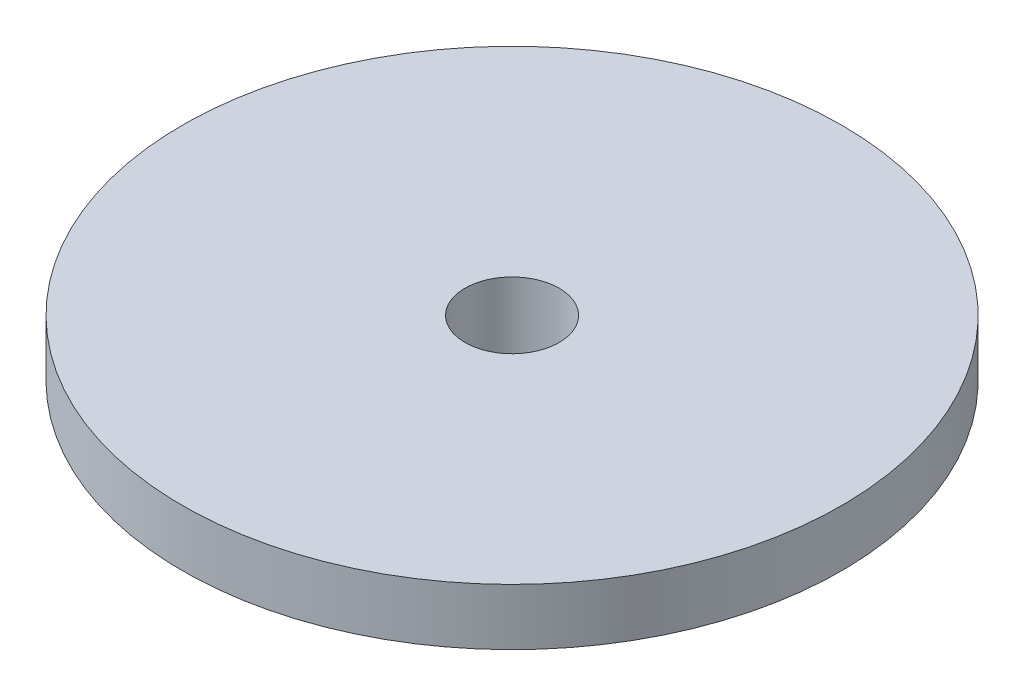
from build123d import *

# Parameters (mm, degrees)
SKETCH10_R         = 2.5
CUT_EXTRUDE1_DEPTH = 11
SKETCH11_R         = 4.5
CUT_EXTRUDE2_DEPTH = 5


with BuildPart() as part:
    # Sketch1 → Revolve1 (revolve)
    with BuildSketch(Plane.XY):
        Polygon((0, 0), (0, 10), (17.5, 10), (17.5, 7), (7, 0), align=None)
    revolve(axis=Axis((0, 0, 0), (0, 1, 0)))

    # Sketch10 → Cut-Extrude1 (cut, through all)
    with BuildSketch(Plane.XZ):
        Circle(SKETCH10_R)
    extrude(amount=-CUT_EXTRUDE1_DEPTH, mode=Mode.SUBTRACT)

    # Sketch11 → Cut-Extrude2 (cut)
    with BuildSketch(Plane.XZ):
        Circle(SKETCH11_R)
    extrude(amount=-CUT_EXTRUDE2_DEPTH, mode=Mode.SUBTRACT)


solid = part.part
